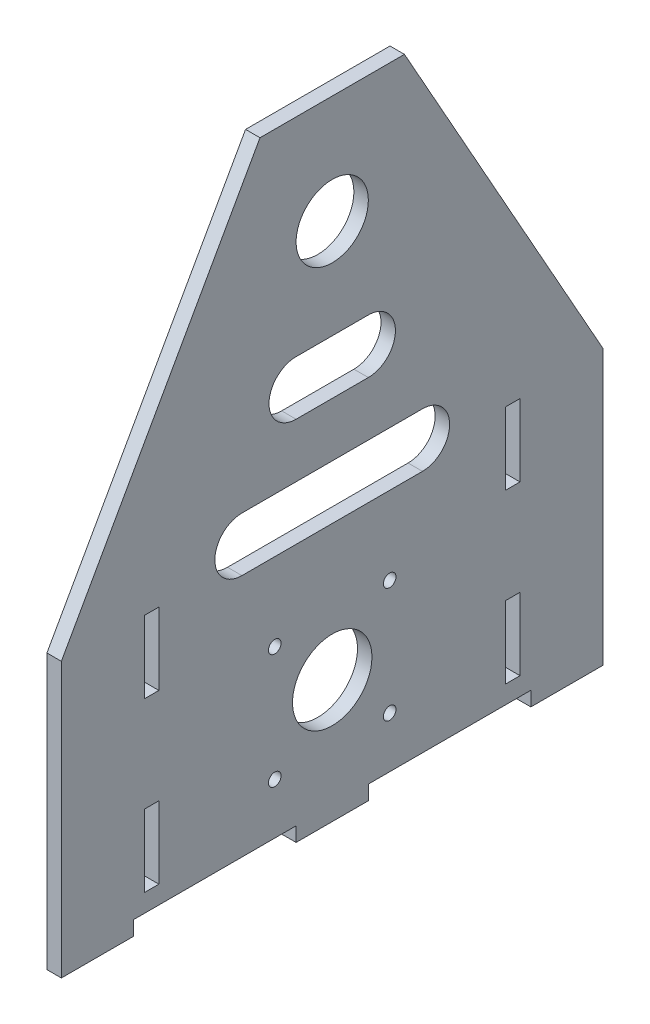
from build123d import *

# Parameters (mm, degrees)
SKETCH1_R           = 11
SKETCH1_R_2         = 10
SKETCH1_R_3         = 1.75
SKETCH1_W           = 4
SKETCH1_H           = 20
BOSS_EXTRUDE1_DEPTH = 4


with BuildPart() as part:
    # Sketch1 → Boss-Extrude1 (new body)
    with BuildSketch(Plane(origin=(0, 0, 0), x_dir=(0, 0, -1), z_dir=(1, 0, 0))):
        Polygon((-20, 170.087118875), (20, 170.087118875), (75, 72.036415883), (75, -3.912881125), (55, -3.912881125), (55, 0.087118875), (10, 0.087118875), (10, -3.912881125), (-10, -3.912881125), (-10, 0.087118875), (-55, 0.087118875), (-55, -3.912881125), (-75, -3.912881125), (-75, 72.036415883), align=None)
        with Locations((0, 30.087118875)):
            Circle(SKETCH1_R, mode=Mode.SUBTRACT)
        with Locations((0, 140.087118875)):
            Circle(SKETCH1_R_2, mode=Mode.SUBTRACT)
        with Locations((-15.909902577, 45.997021452)):
            Circle(SKETCH1_R_3, mode=Mode.SUBTRACT)
        with Locations((-15.909902577, 14.177216298)):
            Circle(SKETCH1_R_3, mode=Mode.SUBTRACT)
        with Locations((15.909902577, 14.177216298)):
            Circle(SKETCH1_R_3, mode=Mode.SUBTRACT)
        with Locations((15.909902577, 45.997021452)):
            Circle(SKETCH1_R_3, mode=Mode.SUBTRACT)
        with BuildLine():
            Line((-10, 112.587118875), (10, 112.587118875))
            ThreePointArc((10, 112.587118875), (17.5, 105.087118875), (10, 97.587118875))
            Line((10, 97.587118875), (-10, 97.587118875))
            ThreePointArc((-10, 97.587118875), (-17.5, 105.087118875), (-10, 112.587118875))
        make_face(mode=Mode.SUBTRACT)
        with BuildLine():
            Line((-25, 82.587118875), (25, 82.587118875))
            ThreePointArc((25, 82.587118875), (32.5, 75.087118875), (25, 67.587118875))
            Line((25, 67.587118875), (-25, 67.587118875))
            ThreePointArc((-25, 67.587118875), (-32.5, 75.087118875), (-25, 82.587118875))
        make_face(mode=Mode.SUBTRACT)
        with Locations((-50, 15.087118875)):
            Rectangle(SKETCH1_W, SKETCH1_H, mode=Mode.SUBTRACT)
        with Locations((50, 15.087118875)):
            Rectangle(SKETCH1_W, SKETCH1_H, mode=Mode.SUBTRACT)
        with Locations((-50, 61.549860891)):
            Rectangle(SKETCH1_W, SKETCH1_H, mode=Mode.SUBTRACT)
        with Locations((50, 61.549860891)):
            Rectangle(SKETCH1_W, SKETCH1_H, mode=Mode.SUBTRACT)
    extrude(amount=BOSS_EXTRUDE1_DEPTH)


solid = part.part
